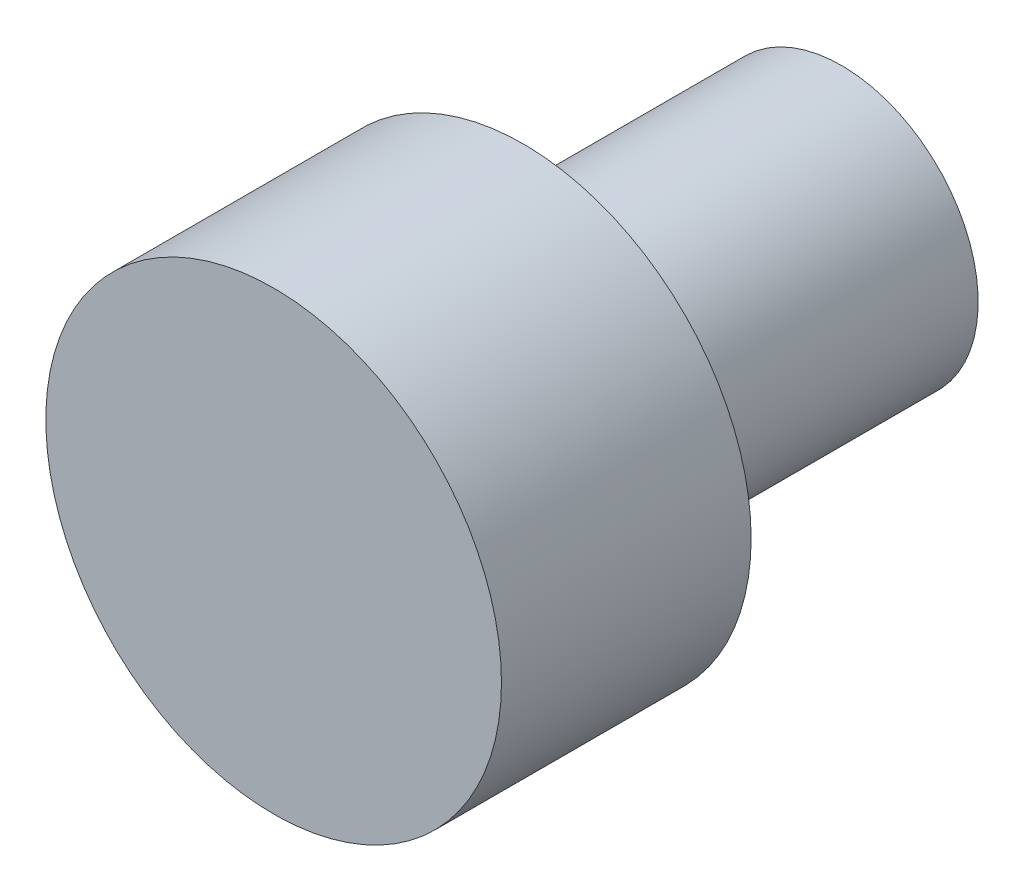
from build123d import *

# Parameters (mm, degrees)
SKETCH1_R           = 9.271
BOSS_EXTRUDE1_DEPTH = 10.16
SKETCH2_R           = 5.55625
BOSS_EXTRUDE2_DEPTH = 12.954


with BuildPart() as part:
    # Sketch1 → Boss-Extrude1 (new body)
    with BuildSketch(Plane.XY):
        Circle(SKETCH1_R)
    extrude(amount=BOSS_EXTRUDE1_DEPTH)

    # Sketch2 → Boss-Extrude2 (add)
    with BuildSketch(Plane(origin=(0, 0, 0), x_dir=(-1, 0, 0), z_dir=(0, 0, -1))):
        Circle(SKETCH2_R)
    extrude(amount=BOSS_EXTRUDE2_DEPTH)


solid = part.part
